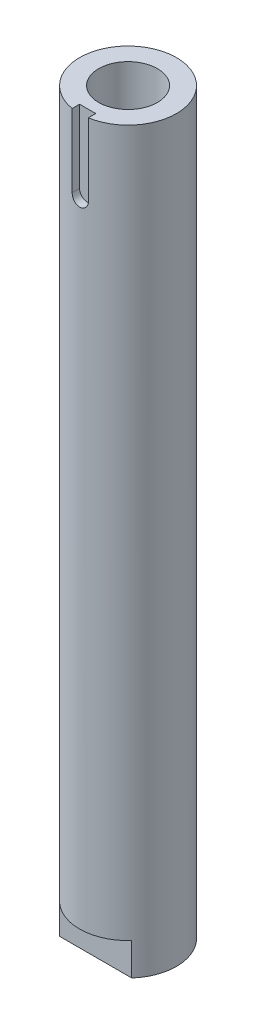
from build123d import *

# Parameters (mm, degrees)
SKETCH1_R                       = 9.5
BOSS_EXTRUDE1_DEPTH             = 144.78
CUT_EXTRUDE1_DEPTH              = 6.35
TAP_DRILL_FOR_1_4_20_TAP1_D     = 5.1054
TAP_DRILL_FOR_1_4_20_TAP1_DEPTH = 31.75
TAP_DRILL_FOR_1_4_20_TAP1_TIP   = 1.533816902
TAP_DRILL_FOR_1_2_20_TAP1_D     = 11.50874
TAP_DRILL_FOR_1_2_20_TAP1_DEPTH = 31.75
TAP_DRILL_FOR_1_2_20_TAP1_TIP   = 3.45757432
CUT_EXTRUDE2_DEPTH              = 1.5875


with BuildPart() as part:
    # Sketch1 → Boss-Extrude1 (new body)
    with BuildSketch(Plane(origin=(0, 0, 0), x_dir=(1, 0, 0), z_dir=(0, 1, 0))):
        Circle(SKETCH1_R)
    extrude(amount=BOSS_EXTRUDE1_DEPTH)

    # Sketch2 → Cut-Extrude1 (cut)
    with BuildSketch(Plane(origin=(0, 0, 0), x_dir=(-1, 0, 0), z_dir=(0, -1, 0))):
        with BuildLine():
            Line((7.065939428, -6.35), (-7.065939428, -6.35))
            ThreePointArc((-7.065939428, -6.35), (0, -9.5), (7.065939428, -6.35))
        make_face()
        with BuildLine():
            Line((7.065939428, 6.35), (-7.065939428, 6.35))
            ThreePointArc((-7.065939428, 6.35), (0, 9.5), (7.065939428, 6.35))
        make_face()
    extrude(amount=-CUT_EXTRUDE1_DEPTH, mode=Mode.SUBTRACT)

    # Tap Drill for 1/4-20 Tap1
    with Locations(Plane(origin=(0, 0, 0), x_dir=(-1, 0, 0), z_dir=(0, -1, 0))):
        with Locations((0, 0)):
            Hole(TAP_DRILL_FOR_1_4_20_TAP1_D / 2, depth=TAP_DRILL_FOR_1_4_20_TAP1_DEPTH)
            with Locations((0, 0, -(TAP_DRILL_FOR_1_4_20_TAP1_DEPTH + TAP_DRILL_FOR_1_4_20_TAP1_TIP / 2))):  # 118° drill point
                Cone(0, TAP_DRILL_FOR_1_4_20_TAP1_D / 2, TAP_DRILL_FOR_1_4_20_TAP1_TIP, mode=Mode.SUBTRACT)

    # Tap Drill for 1/2-20 Tap1
    with Locations(Plane(origin=(0, 144.78, 0), x_dir=(1, 0, 0), z_dir=(0, 1, 0))):
        with Locations((0, 0)):
            Hole(TAP_DRILL_FOR_1_2_20_TAP1_D / 2, depth=TAP_DRILL_FOR_1_2_20_TAP1_DEPTH)
            with Locations((0, 0, -(TAP_DRILL_FOR_1_2_20_TAP1_DEPTH + TAP_DRILL_FOR_1_2_20_TAP1_TIP / 2))):  # 118° drill point
                Cone(0, TAP_DRILL_FOR_1_2_20_TAP1_D / 2, TAP_DRILL_FOR_1_2_20_TAP1_TIP, mode=Mode.SUBTRACT)

    # Sketch7 → Cut-Extrude2 (cut)
    with BuildSketch(Plane.XY.offset(9.5)):
        with BuildLine():
            Line((-1.5875, 130.4925), (-1.5875, 144.78))
            Line((-1.5875, 144.78), (1.5875, 144.78))
            Line((1.5875, 144.78), (1.5875, 130.4925))
            ThreePointArc((1.5875, 130.4925), (0, 128.905), (-1.5875, 130.4925))
        make_face()
    extrude(amount=-CUT_EXTRUDE2_DEPTH, mode=Mode.SUBTRACT)


solid = part.part
